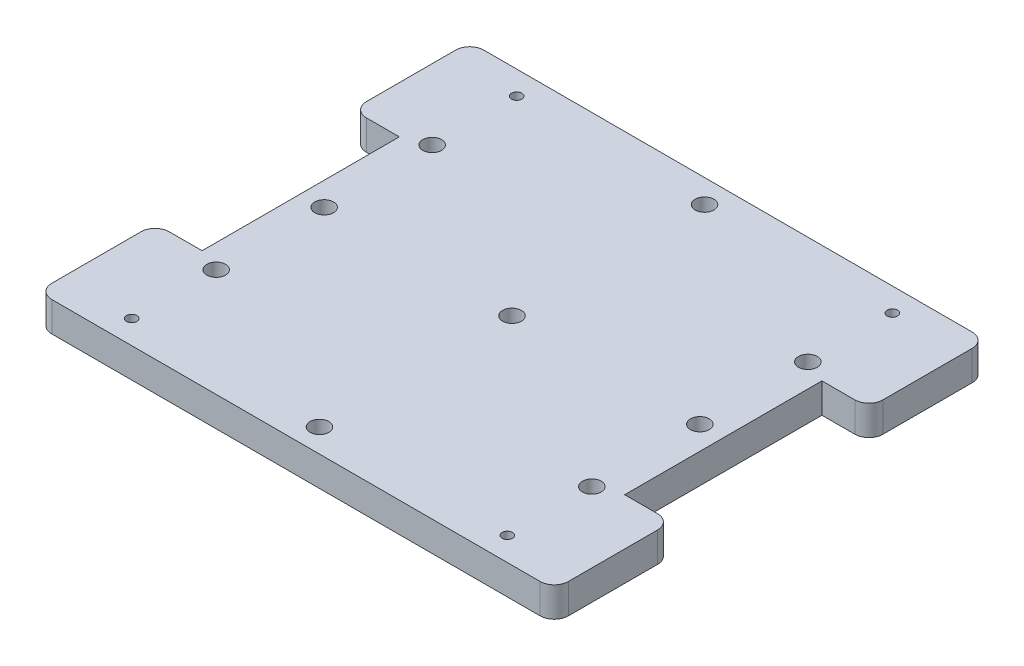
from build123d import *

# Parameters (mm, degrees)
SKETCH1_W               = 90
SKETCH1_H               = 46
SKETCH1_R               = 1.1
BOSS_EXTRUDE1_DEPTH     = 6.35
SKETCH2_W               = 25
SKETCH2_H               = 6.35
BOSS_EXTRUDE2_DEPTH     = 10
FILLET1_R               = 3
MIRROR2_COPY_1_SKETCH_W = 90
MIRROR2_COPY_1_SKETCH_H = 46
MIRROR2_COPY_1_SKETCH_R = 1.1
MIRROR2_COPY_1_DEPTH    = 6.35
FILLET1_OF_MIRROR2_R    = 3
SKETCH3_R               = 2
CUT_EXTRUDE1_DEPTH      = 6.35
SKETCH4_R               = 2
CUT_EXTRUDE2_DEPTH      = 6.35
SKETCH5_R               = 2
CUT_EXTRUDE3_DEPTH      = 6.35
SKETCH6_R               = 2
CUT_EXTRUDE4_DEPTH      = 6.35


with BuildPart() as part:
    # Sketch1 → Boss-Extrude1 (new body)
    with BuildSketch(Plane(origin=(0, 0, 0), x_dir=(1, 0, 0), z_dir=(0, 1, 0))):
        with Locations((45, 23)):
            Rectangle(SKETCH1_W, SKETCH1_H)
        with Locations((85, 5)):
            Circle(SKETCH1_R, mode=Mode.SUBTRACT)
        with Locations((5, 5)):
            Circle(SKETCH1_R, mode=Mode.SUBTRACT)
    boss_extrude1 = extrude(amount=BOSS_EXTRUDE1_DEPTH)

    # Mirror1: Boss-Extrude1 across plane
    add(boss_extrude1.mirror(Plane(origin=(0, 0, -46), x_dir=(1, 0, 0), z_dir=(0, 0, -1))))

    # Sketch2 → Boss-Extrude2 (add)
    with BuildSketch(Plane(origin=(90, 0, 0), x_dir=(0, 0, -1), z_dir=(1, 0, 0))):
        with Locations((12.5, 3.175)):
            Rectangle(SKETCH2_W, SKETCH2_H)
        with Locations((79.5, 3.175)):
            Rectangle(SKETCH2_W, SKETCH2_H)
    boss_extrude2 = extrude(amount=BOSS_EXTRUDE2_DEPTH)

    # Fillet1
    fillet1_edges = [part.edges().sort_by_distance(p)[0] for p in [
        (100, 3.175, 0),
        (100, 3.175, -25),
        (100, 3.175, -92),
        (100, 3.175, -67),
    ]]
    fillet(fillet1_edges, radius=FILLET1_R)

    # Mirror2: Boss-Extrude1, Boss-Extrude2 across plane
    add(boss_extrude1.mirror(Plane(origin=(45, 0, 0), x_dir=(0, 0, 1), z_dir=(1, 0, 0))))
    add(boss_extrude2.mirror(Plane(origin=(45, 0, 0), x_dir=(0, 0, 1), z_dir=(1, 0, 0))))

    # Mirror2 copy 1 sketch → Mirror2 copy 1 (add)
    with BuildSketch(Plane(origin=(90, 0, -92), x_dir=(-1, 0, 0), z_dir=(0, 1, 0))):
        with Locations((45, 23)):
            Rectangle(MIRROR2_COPY_1_SKETCH_W, MIRROR2_COPY_1_SKETCH_H)
        with Locations((85, 5)):
            Circle(MIRROR2_COPY_1_SKETCH_R, mode=Mode.SUBTRACT)
        with Locations((5, 5)):
            Circle(MIRROR2_COPY_1_SKETCH_R, mode=Mode.SUBTRACT)
    extrude(amount=MIRROR2_COPY_1_DEPTH)

    # Fillet1 of Mirror2
    fillet1_of_mirror2_edges = [part.edges().sort_by_distance(p)[0] for p in [
        (-10, 3.175, 0),
        (-10, 3.175, -25),
        (-10, 3.175, -92),
        (-10, 3.175, -67),
    ]]
    fillet(fillet1_of_mirror2_edges, radius=FILLET1_OF_MIRROR2_R)

    # Sketch3 → Cut-Extrude1 (cut)
    with BuildSketch(Plane(origin=(0, 6.35, 0), x_dir=(1, 0, 0), z_dir=(0, 1, 0))):
        with Locations((5, 69)):
            Circle(SKETCH3_R)
        with Locations((85, 69)):
            Circle(SKETCH3_R)
    extrude(amount=-CUT_EXTRUDE1_DEPTH, mode=Mode.SUBTRACT)

    # Sketch4 → Cut-Extrude2 (cut)
    with BuildSketch(Plane(origin=(0, 6.35, 0), x_dir=(1, 0, 0), z_dir=(0, 1, 0))):
        with Locations((5, 23)):
            Circle(SKETCH4_R)
        with Locations((85, 23)):
            Circle(SKETCH4_R)
    extrude(amount=-CUT_EXTRUDE2_DEPTH, mode=Mode.SUBTRACT)

    # Sketch5 → Cut-Extrude3 (cut)
    with BuildSketch(Plane(origin=(0, 6.35, 0), x_dir=(1, 0, 0), z_dir=(0, 1, 0))):
        with Locations((45, 5)):
            Circle(SKETCH5_R)
        with Locations((45, 87)):
            Circle(SKETCH5_R)
    extrude(amount=-CUT_EXTRUDE3_DEPTH, mode=Mode.SUBTRACT)

    # Sketch6 → Cut-Extrude4 (cut)
    with BuildSketch(Plane(origin=(0, 6.35, 0), x_dir=(1, 0, 0), z_dir=(0, 1, 0))):
        with Locations((85, 46)):
            Circle(SKETCH6_R)
        with Locations((45, 46)):
            Circle(SKETCH6_R)
        with Locations((5, 46)):
            Circle(SKETCH6_R)
    extrude(amount=-CUT_EXTRUDE4_DEPTH, mode=Mode.SUBTRACT)


solid = part.part
